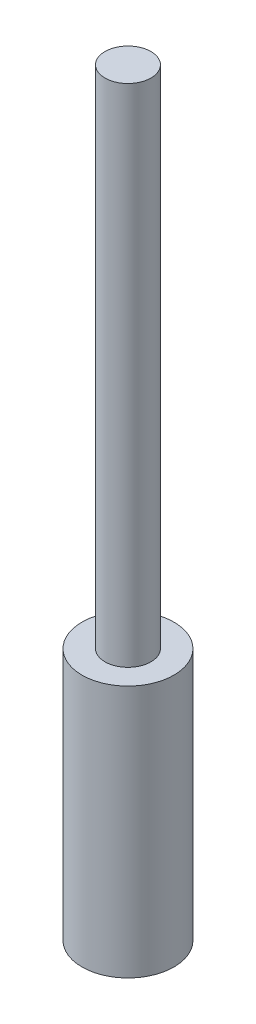
from build123d import *

# Parameters (mm, degrees)
SKETCH1_R           = 10
BOSS_EXTRUDE1_DEPTH = 55
SKETCH2_R           = 5
BOSS_EXTRUDE2_DEPTH = 110


with BuildPart() as part:
    # Sketch1 → Boss-Extrude1 (new body)
    with BuildSketch(Plane(origin=(0, 0, 0), x_dir=(1, 0, 0), z_dir=(0, 1, 0))):
        Circle(SKETCH1_R)
    extrude(amount=BOSS_EXTRUDE1_DEPTH)

    # Sketch2 → Boss-Extrude2 (add)
    with BuildSketch(Plane(origin=(0, 55, 0), x_dir=(1, 0, 0), z_dir=(0, 1, 0))):
        Circle(SKETCH2_R)
    extrude(amount=BOSS_EXTRUDE2_DEPTH)


solid = part.part
